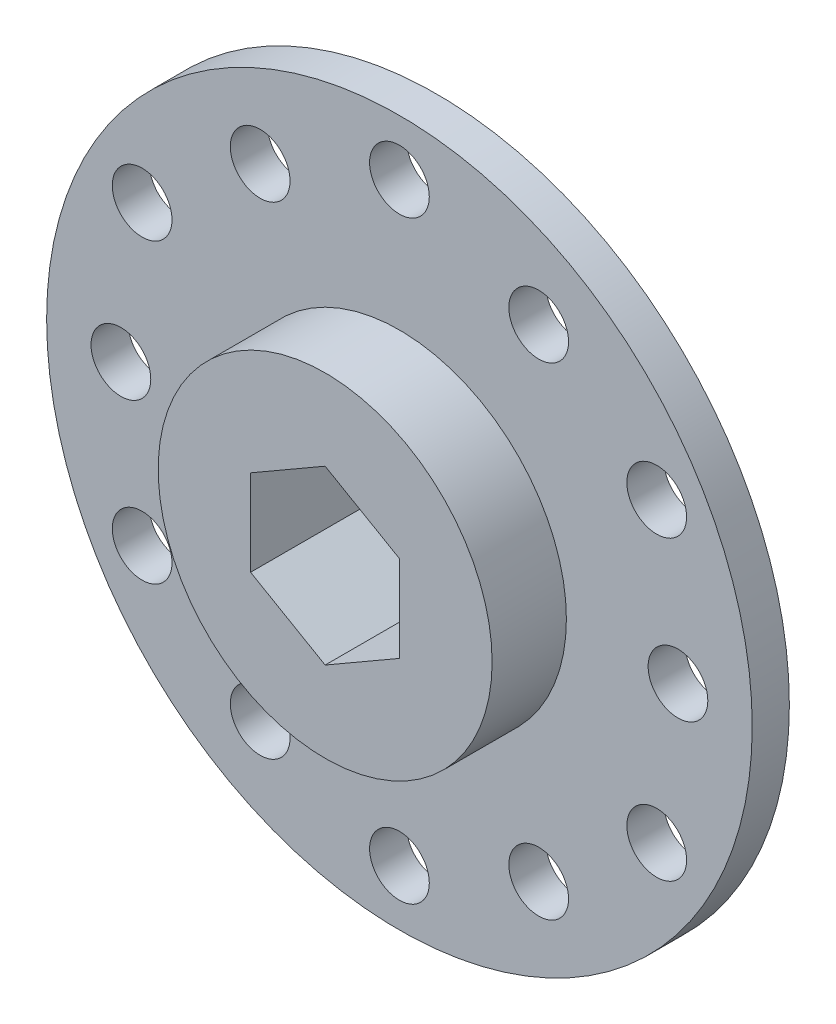
from build123d import *

# Parameters (mm, degrees)
SKETCH1_W           = 30.1625
SKETCH1_H           = 3.175
SKETCH2_R           = 14.2748
BOSS_EXTRUDE1_DEPTH = 6.35
CUT_EXTRUDE1_DEPTH  = 10.525
HOLE1_D             = 5.1054
HOLE1_DEPTH         = 9.525


with BuildPart() as part:
    # Sketch1 → Revolve1 (revolve)
    with BuildSketch(Plane(origin=(0, 0, 0), x_dir=(1, 0, 0), z_dir=(0, 1, 0))):
        with Locations((15.08125, -1.5875)):
            Rectangle(SKETCH1_W, SKETCH1_H)
    revolve(axis=Axis((0, 0, 0), (0, 0, 1)))

    # Sketch2 → Boss-Extrude1 (add)
    with BuildSketch(Plane.XY.offset(3.175)):
        Circle(SKETCH2_R)
    extrude(amount=BOSS_EXTRUDE1_DEPTH)

    # Sketch3 → Cut-Extrude1 (cut, through all)
    with BuildSketch(Plane.XY.offset(9.525)):
        Polygon((0, -7.361677812), (6.3754, -3.680838906), (6.3754, 3.680838906), (0, 7.361677812), (-6.3754, 3.680838906), (-6.3754, -3.680838906), align=None)
    extrude(amount=-CUT_EXTRUDE1_DEPTH, mode=Mode.SUBTRACT)

    # Hole1
    with Locations(Plane(origin=(0, 0, 0), x_dir=(-1, 0, 0), z_dir=(0, 0, -1))):
        with Locations((11.90625, 20.622229928), (0, 25.4), (23.8125, 0), (21.997045256, 12.7), (11.90625, -20.622229928), (21.997045256, -12.7), (-11.90625, -20.622229928), (0, -25.4), (-23.8125, 0), (-21.997045256, -12.7), (-11.90625, 20.622229928), (-21.997045256, 12.7)):
            Hole(HOLE1_D / 2, depth=HOLE1_DEPTH)


solid = part.part
